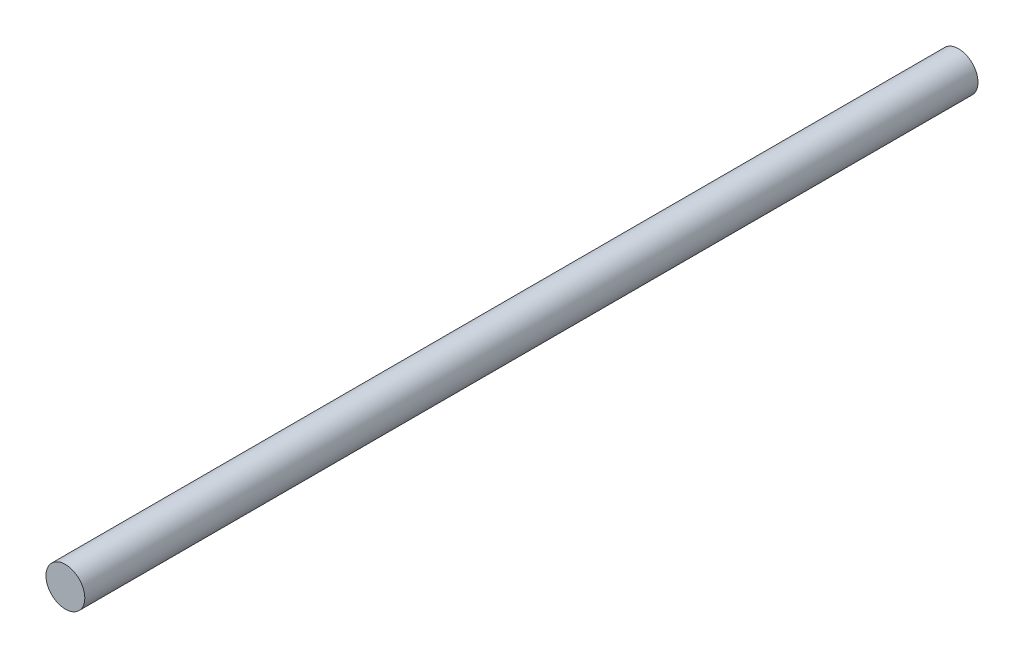
from build123d import *

# Parameters (mm, degrees)
SKETCH1_R           = 6.35
BOSS_EXTRUDE1_DEPTH = 146.05


with BuildPart() as part:
    # Sketch1 → Boss-Extrude1 (new body, symmetric)
    with BuildSketch(Plane.XY):
        Circle(SKETCH1_R)
    extrude(amount=BOSS_EXTRUDE1_DEPTH, both=True)


solid = part.part
